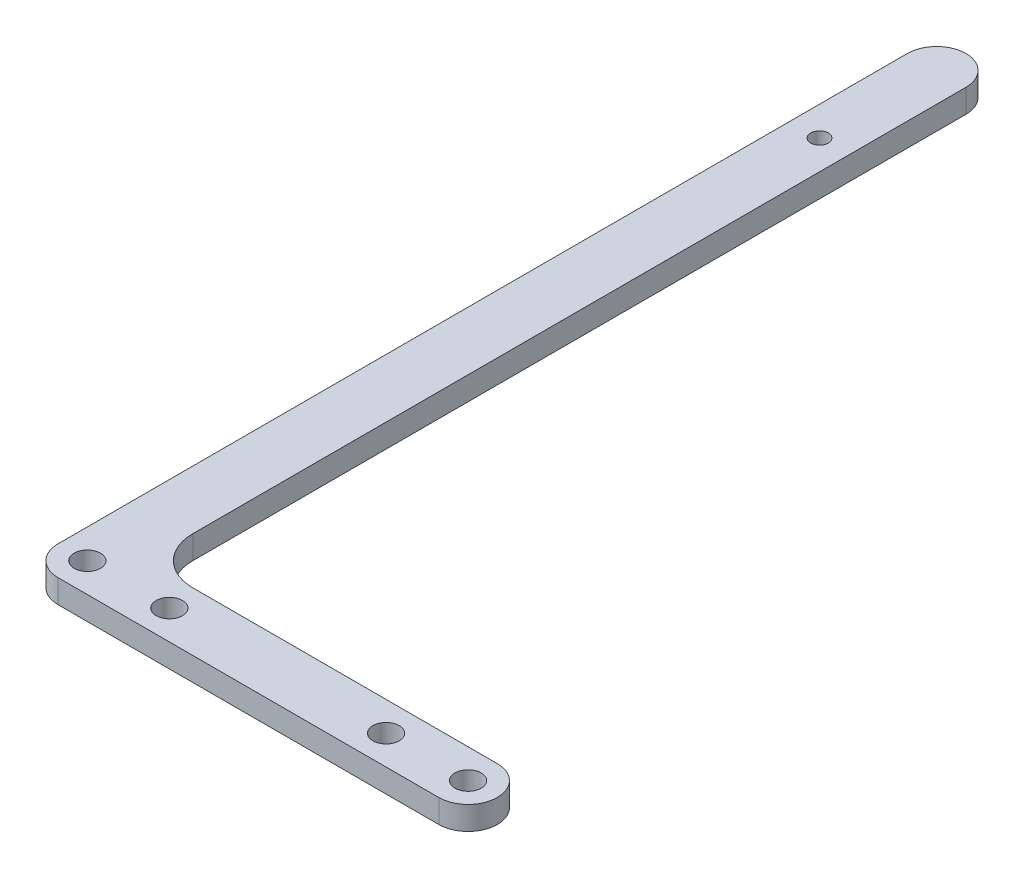
from build123d import *

# Parameters (mm, degrees)
SKETCH1_R           = 1.5
BOSS_EXTRUDE1_DEPTH = 4
SKETCH2_R           = 2.25
BOSS_EXTRUDE2_DEPTH = 4
FILLET1_R           = 8
FILLET2_R           = 5


with BuildPart() as part:
    # Sketch1 → Boss-Extrude1 (new body)
    with BuildSketch(Plane(origin=(0, 0, 0), x_dir=(1, 0, 0), z_dir=(0, 1, 0))):
        with BuildLine():
            Line((10, 140), (10, 0))
            Line((10, 0), (0, 0))
            Line((0, 0), (0, 140))
            ThreePointArc((0, 140), (5, 145), (10, 140))
        make_face()
        with Locations((5, 120)):
            Circle(SKETCH1_R, mode=Mode.SUBTRACT)
    extrude(amount=BOSS_EXTRUDE1_DEPTH)

    # Sketch2 → Boss-Extrude2 (add)
    with BuildSketch(Plane(origin=(0, 4, 0), x_dir=(1, 0, 0), z_dir=(0, 1, 0))):
        with BuildLine():
            Line((70, 0), (10, 0))
            Line((10, 0), (0, 0))
            Line((0, 0), (0, -10))
            Line((0, -10), (70, -10))
            ThreePointArc((70, -10), (75, -5), (70, 0))
        make_face()
        with Locations((5, -5)):
            Circle(SKETCH2_R, mode=Mode.SUBTRACT)
        with Locations((19, -5)):
            Circle(SKETCH2_R, mode=Mode.SUBTRACT)
        with Locations((56, -5)):
            Circle(SKETCH2_R, mode=Mode.SUBTRACT)
        with Locations((70, -5)):
            Circle(SKETCH2_R, mode=Mode.SUBTRACT)
    extrude(amount=-BOSS_EXTRUDE2_DEPTH)

    # Fillet1
    fillet1_edges = [part.edges().sort_by_distance(p)[0] for p in [
        (10, 2, 0),
    ]]
    fillet(fillet1_edges, radius=FILLET1_R)

    # Fillet2
    fillet2_edges = [part.edges().sort_by_distance(p)[0] for p in [
        (0, 2, 10),
    ]]
    fillet(fillet2_edges, radius=FILLET2_R)


solid = part.part
